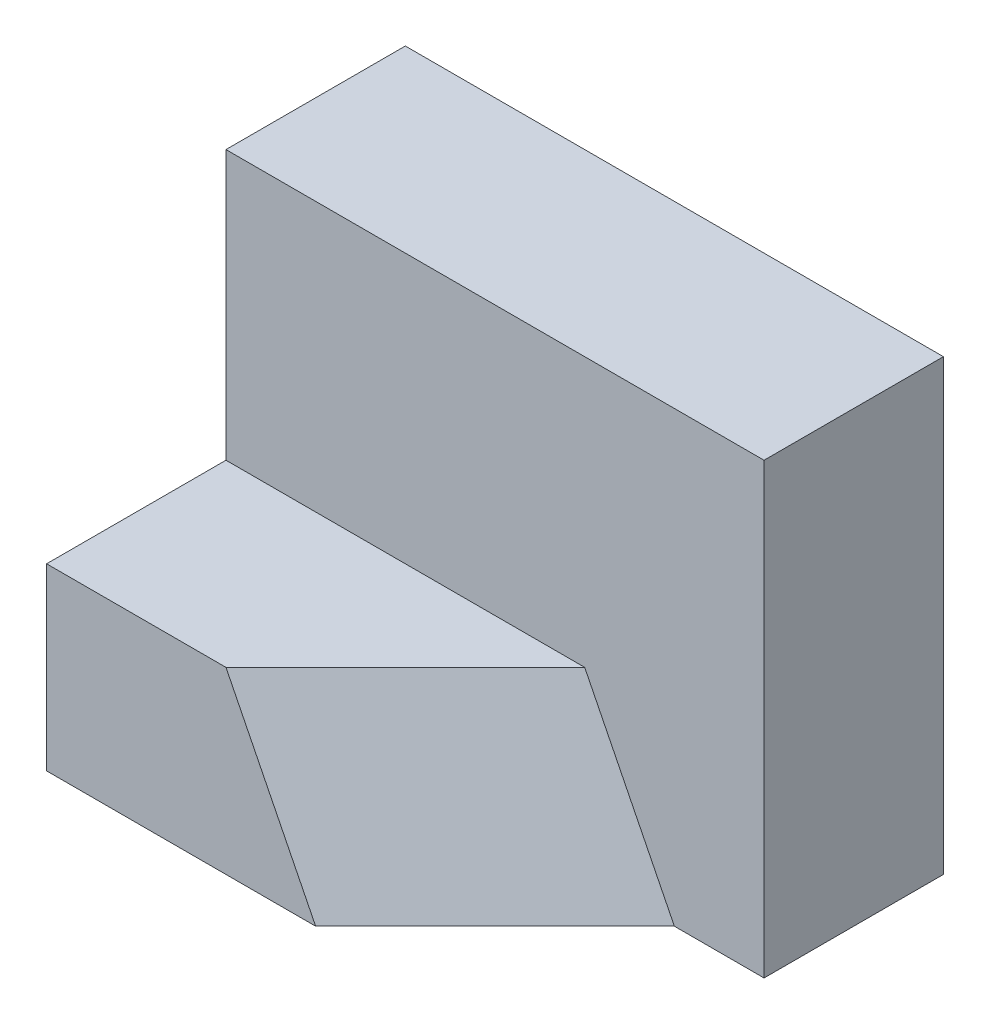
from build123d import *

# Parameters (mm, degrees)
SKETCH1_W           = 6
SKETCH1_H           = 5
BOSS_EXTRUDE1_DEPTH = 2
BOSS_EXTRUDE2_DEPTH = 2
CUT_EXTRUDE1_DEPTH  = 10


with BuildPart() as part:
    # Sketch1 → Boss-Extrude1 (new body)
    with BuildSketch(Plane.XY):
        with Locations((3, 2.5)):
            Rectangle(SKETCH1_W, SKETCH1_H)
    extrude(amount=BOSS_EXTRUDE1_DEPTH)

    # Sketch2 → Boss-Extrude2 (add)
    with BuildSketch(Plane.XY.offset(2)):
        Polygon((0, 0), (0, 2), (4, 2), (6, 0), align=None)
    extrude(amount=BOSS_EXTRUDE2_DEPTH)

    # 3DSketch1 → Cut-Extrude1 (cut, along a direction that is not the sketch's normal)
    with BuildSketch(Plane(origin=(5, 0, 2), x_dir=(-0.727606875108999, 0.485071250072666, 0.485071250072666), z_dir=(0.6666666666666666, 0.3333333333333333, 0.6666666666666666))):
        Polygon((0, 0), (2.42535625, 1.45521375), (4.123105626, 0), (1.697749375, -1.45521375), align=None)
    extrude(amount=CUT_EXTRUDE1_DEPTH, dir=(1, 0, 0), mode=Mode.SUBTRACT)


solid = part.part
